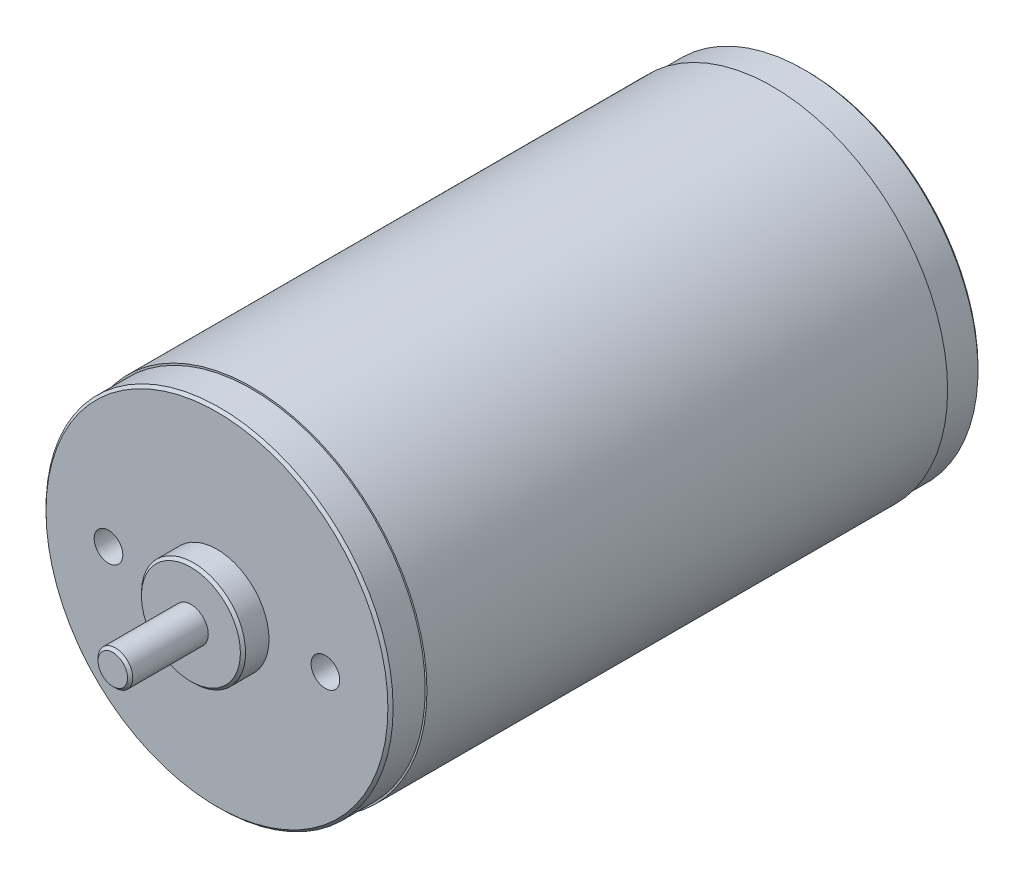
from build123d import *

# Parameters (mm, degrees)
SKETCH1_W                      = 20.2
SKETCH1_H                      = 60
SKETCH2_R                      = 20
BOSS_EXTRUDE1_DEPTH            = 4
SKETCH3_R                      = 6
BOSS_EXTRUDE2_DEPTH            = 3
SKETCH4_R                      = 2
BOSS_EXTRUDE3_DEPTH            = 9
SKETCH5_R                      = 20
BOSS_EXTRUDE4_DEPTH            = 4
SKETCH6_R                      = 6.325
BOSS_EXTRUDE5_DEPTH            = 1.5
F_3_3_3_3_DIAMETER_HOLE1_D     = 3.3
F_3_3_3_3_DIAMETER_HOLE1_DEPTH = 8.1
F_3_3_3_3_DIAMETER_HOLE1_TIP   = 0.991420021
CHAMFER1_SIZE                  = 0.3


with BuildPart() as part:
    # Sketch1 → Revolve1 (revolve)
    with BuildSketch(Plane(origin=(0, 0, 0), x_dir=(1, 0, 0), z_dir=(0, 1, 0))):
        with Locations((10.1, 34)):
            Rectangle(SKETCH1_W, SKETCH1_H)
    revolve(axis=Axis((0, 0, -64), (0, 0, 1)))

    # Sketch2 → Boss-Extrude1 (add)
    with BuildSketch(Plane.XY.offset(-4)):
        Circle(SKETCH2_R)
    extrude(amount=BOSS_EXTRUDE1_DEPTH)

    # Sketch3 → Boss-Extrude2 (add)
    with BuildSketch(Plane.XY):
        Circle(SKETCH3_R)
    extrude(amount=BOSS_EXTRUDE2_DEPTH)

    # Sketch4 → Boss-Extrude3 (add)
    with BuildSketch(Plane.XY.offset(3)):
        Circle(SKETCH4_R)
    extrude(amount=BOSS_EXTRUDE3_DEPTH)

    # Sketch5 → Boss-Extrude4 (add)
    with BuildSketch(Plane(origin=(0, 0, -64), x_dir=(-1, 0, 0), z_dir=(0, 0, -1))):
        Circle(SKETCH5_R)
    extrude(amount=BOSS_EXTRUDE4_DEPTH)

    # Sketch6 → Boss-Extrude5 (add)
    with BuildSketch(Plane(origin=(0, 0, -68), x_dir=(-1, 0, 0), z_dir=(0, 0, -1))):
        Circle(SKETCH6_R)
    extrude(amount=BOSS_EXTRUDE5_DEPTH)

    # Ø3.3 (3.3) Diameter Hole1
    with Locations(Plane.XY):
        with Locations((-12.5, 0), (12.5, 0)):
            Hole(F_3_3_3_3_DIAMETER_HOLE1_D / 2, depth=F_3_3_3_3_DIAMETER_HOLE1_DEPTH)
            with Locations((0, 0, -(F_3_3_3_3_DIAMETER_HOLE1_DEPTH + F_3_3_3_3_DIAMETER_HOLE1_TIP / 2))):  # 118° drill point
                Cone(0, F_3_3_3_3_DIAMETER_HOLE1_D / 2, F_3_3_3_3_DIAMETER_HOLE1_TIP, mode=Mode.SUBTRACT)

    # Chamfer1
    chamfer1_edges = [part.edges().sort_by_distance(p)[0] for p in [
        (-6, 0, 3),
        (-2, 0, 12),
        (20, 0, -68),
        (6.325, 0, -69.5),
        (-20, 0, 0),
    ]]
    chamfer(chamfer1_edges, length=CHAMFER1_SIZE)


solid = part.part
